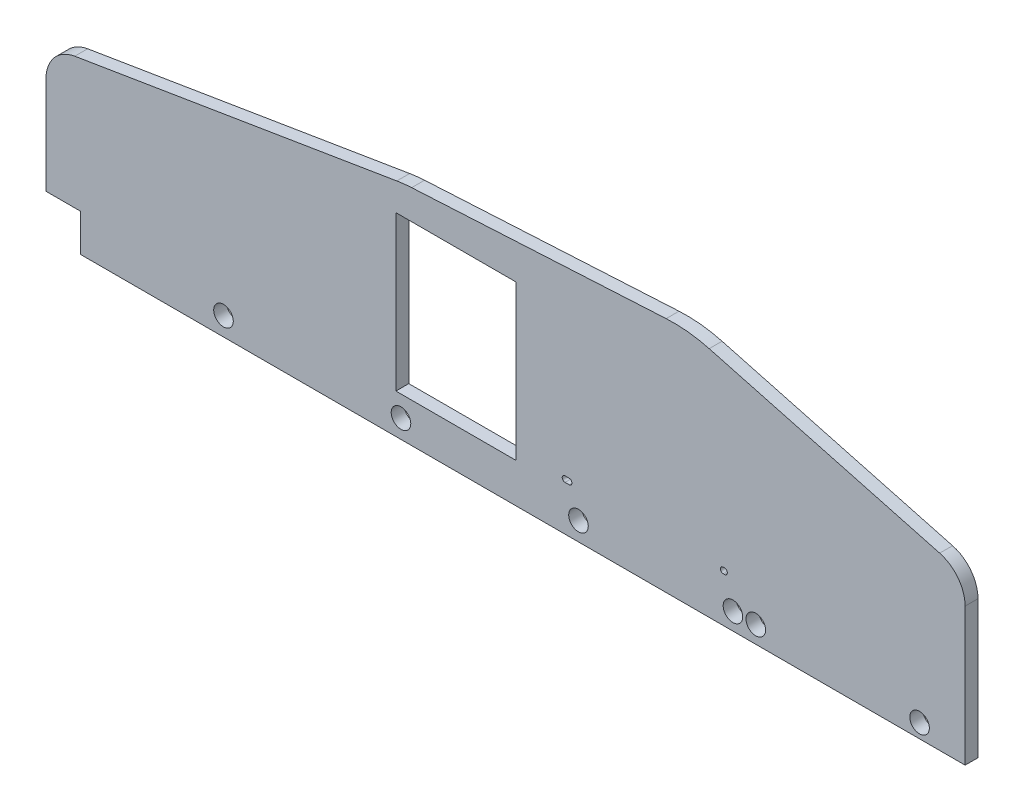
from build123d import *

# Parameters (mm, degrees)
SKETCH2_R           = 7.239
BOSS_EXTRUDE1_DEPTH = 4.7625
FILLET1_R           = 25.4
FILLET2_R           = 101.6
SKETCH3_W           = 25.4
SKETCH3_H           = 27.686
CUT_EXTRUDE1_DEPTH  = 10.525
SKETCH5_W           = 88.9
SKETCH5_H           = 114.3
CUT_EXTRUDE2_DEPTH  = 10.525
CUT_EXTRUDE3_DEPTH  = 10.525


with BuildPart() as part:
    # Sketch2 → Boss-Extrude1 (new body, symmetric)
    with BuildSketch(Plane.XY):
        Polygon((-340, 26.400000032), (-340, 121.400000032), (-75, 165), (135, 176.400000032), (340, 121.400000032), (340, 26.400000032), (340, 0), (-340, 0), align=None)
        with Locations((-208.682, 13.700000032)):
            Circle(SKETCH2_R, mode=Mode.SUBTRACT)
        with Locations((-77.364, 13.700000032)):
            Circle(SKETCH2_R, mode=Mode.SUBTRACT)
        with Locations((53.954, 13.700000032)):
            Circle(SKETCH2_R, mode=Mode.SUBTRACT)
        with Locations((185.126699107, 12.7)):
            Circle(SKETCH2_R, mode=Mode.SUBTRACT)
        with Locations((306.284699107, 10.414)):
            Circle(SKETCH2_R, mode=Mode.SUBTRACT)
        with Locations((168.225103232, 12.7)):
            Circle(SKETCH2_R, mode=Mode.SUBTRACT)
    extrude(amount=BOSS_EXTRUDE1_DEPTH, both=True)

    # Fillet1
    fillet1_edges = [part.edges().sort_by_distance(p)[0] for p in [
        (-340, 121.400000032, 0),
        (340, 121.400000032, 0),
    ]]
    fillet(fillet1_edges, radius=FILLET1_R)

    # Fillet2
    fillet2_edges = [part.edges().sort_by_distance(p)[0] for p in [
        (-75, 165, 0),
        (135, 176.400000032, 0),
    ]]
    fillet(fillet2_edges, radius=FILLET2_R)

    # Sketch3 → Cut-Extrude1 (cut, through all)
    with BuildSketch(Plane.XY.offset(4.7625)):
        with Locations((-327.3, 13.843)):
            Rectangle(SKETCH3_W, SKETCH3_H)
    extrude(amount=-CUT_EXTRUDE1_DEPTH, mode=Mode.SUBTRACT)

    # Sketch5 → Cut-Extrude2 (cut, through all)
    with BuildSketch(Plane.XY.offset(4.7625)):
        with Locations((-36.66848567, 86.296499999)):
            Rectangle(SKETCH5_W, SKETCH5_H)
    extrude(amount=-CUT_EXTRUDE2_DEPTH, mode=Mode.SUBTRACT)

    # Sketch8 → Cut-Extrude3 (cut, through all)
    with BuildSketch(Plane.XY.offset(4.7625)):
        with BuildLine():
            Line((161, 37.4), (162, 37.4))
            ThreePointArc((162, 37.4), (164.1, 35.3), (162, 33.2))
            Line((162, 33.2), (161, 33.2))
            ThreePointArc((161, 33.2), (158.9, 35.3), (161, 37.4))
        make_face()
        with BuildLine():
            Line((47, 33.2), (44, 33.2))
            ThreePointArc((44, 33.2), (41.9, 35.3), (44, 37.4))
            Line((44, 37.4), (47, 37.4))
            ThreePointArc((47, 37.4), (49.1, 35.3), (47, 33.2))
        make_face()
    extrude(amount=-CUT_EXTRUDE3_DEPTH, mode=Mode.SUBTRACT)


solid = part.part
